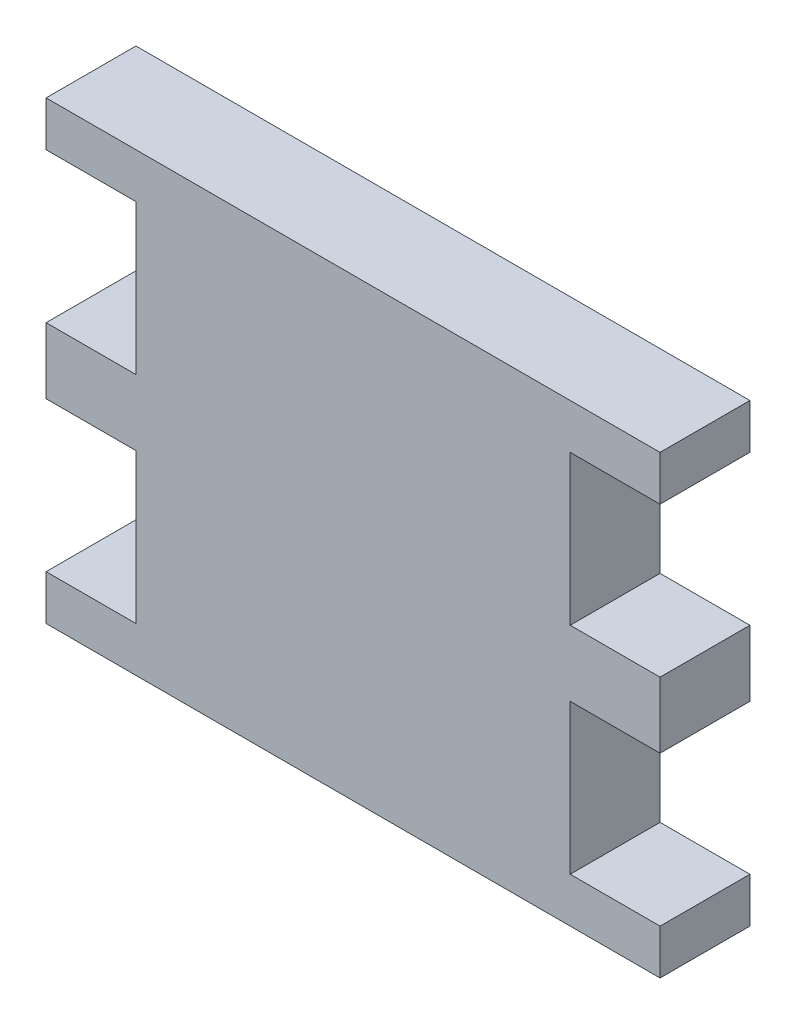
from build123d import *

# Parameters (mm, degrees)
BOSS_EXTRU_1_DEPTH = 6


with BuildPart() as part:
    # Esquisse1 → Boss.-Extru.1 (new body)
    with BuildSketch(Plane.XY):
        Polygon((-20.5, 14.511442786), (20.5, 14.511442786), (20.5, 11.511442786), (14.5, 11.511442786), (14.5, 1.511442786), (20.5, 1.511442786), (20.5, -2.888557214), (14.5, -2.888557214), (14.5, -12.888557214), (20.5, -12.888557214), (20.5, -15.888557214), (-20.5, -15.888557214), (-20.5, -12.888557214), (-14.5, -12.888557214), (-14.5, -2.888557214), (-20.5, -2.888557214), (-20.5, 1.511442786), (-14.5, 1.511442786), (-14.5, 11.511442786), (-20.5, 11.511442786), align=None)
    extrude(amount=BOSS_EXTRU_1_DEPTH)


solid = part.part
